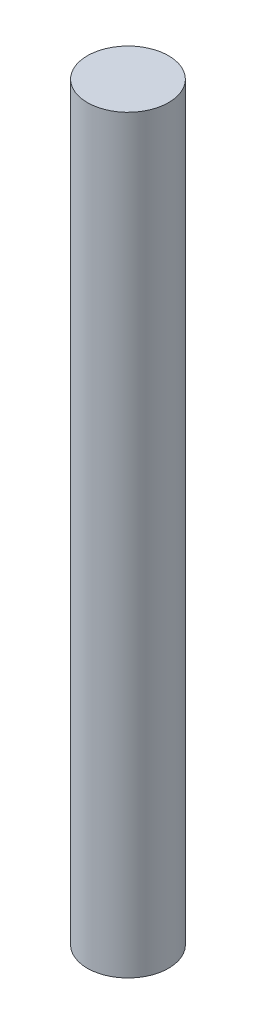
from build123d import *

# Parameters (mm, degrees)
SKETCH1_R           = 1.95
BOSS_EXTRUDE1_DEPTH = 36


with BuildPart() as part:
    # Sketch1 → Boss-Extrude1 (new body)
    with BuildSketch(Plane(origin=(0, 0, 0), x_dir=(1, 0, 0), z_dir=(0, 1, 0))):
        Circle(SKETCH1_R)
    extrude(amount=BOSS_EXTRUDE1_DEPTH)


solid = part.part
